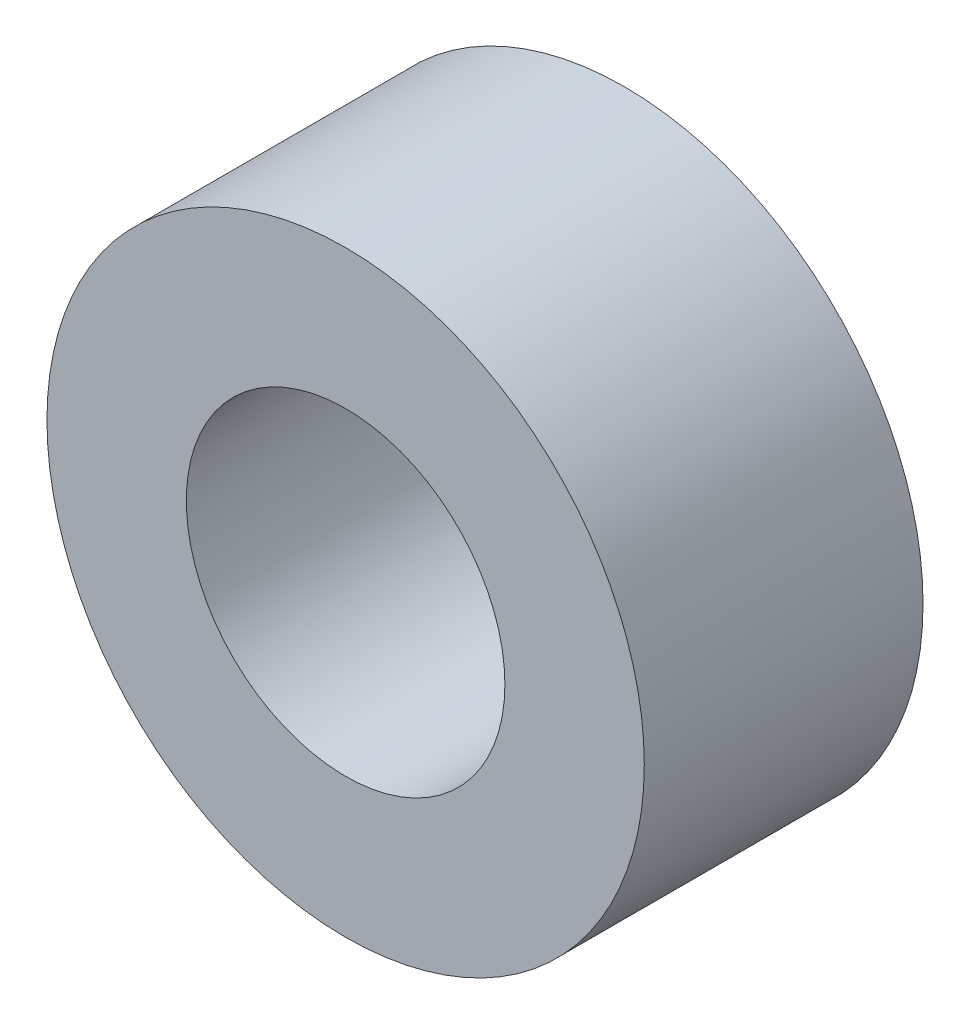
from build123d import *

# Parameters (mm, degrees)
SKETCH1_R           = 7.5
SKETCH1_R_2         = 4
BOSS_EXTRUDE1_DEPTH = 7


with BuildPart() as part:
    # Sketch1 → Boss-Extrude1 (new body)
    with BuildSketch(Plane.XY):
        Circle(SKETCH1_R)
        Circle(SKETCH1_R_2, mode=Mode.SUBTRACT)
    extrude(amount=BOSS_EXTRUDE1_DEPTH)


solid = part.part
